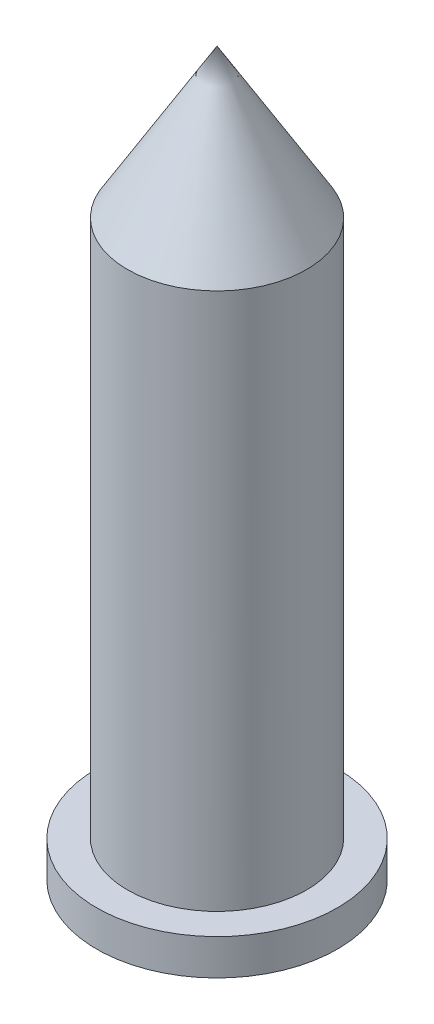
from build123d import *

# Parameters (mm, degrees)
SKETCH1_W           = 5
SKETCH1_H           = 30
SKETCH3_R           = 6.721759799
BOSS_EXTRUDE1_DEPTH = 2


with BuildPart() as part:
    # Sketch1 → Revolve1 (revolve)
    with BuildSketch(Plane(origin=(0, 0, 0), x_dir=(0, 0, -1), z_dir=(1, 0, 0))):
        with Locations((-25.408302522, 49.690625)):
            Rectangle(SKETCH1_W, SKETCH1_H)
    revolve(axis=Axis((0, 64.690625, 22.908302522), (0, -1, 0)))

    # Sketch2 → Revolve5 (revolve)
    with BuildSketch(Plane(origin=(0, 0, 0), x_dir=(0, 0, -1), z_dir=(1, 0, 0))):
        Polygon((-27.908302522, 64.690625), (-22.908302522, 72.998720515), (-22.908302522, 64.690625), align=None)
    revolve(axis=Axis((0, 72.998720515, 22.908302522), (0, -1, 0)))

    # Sketch3 → Boss-Extrude1 (add)
    with BuildSketch(Plane.XZ.offset(-34.690625)):
        with Locations((0, 22.908302522)):
            Circle(SKETCH3_R)
    extrude(amount=BOSS_EXTRUDE1_DEPTH)


solid = part.part
